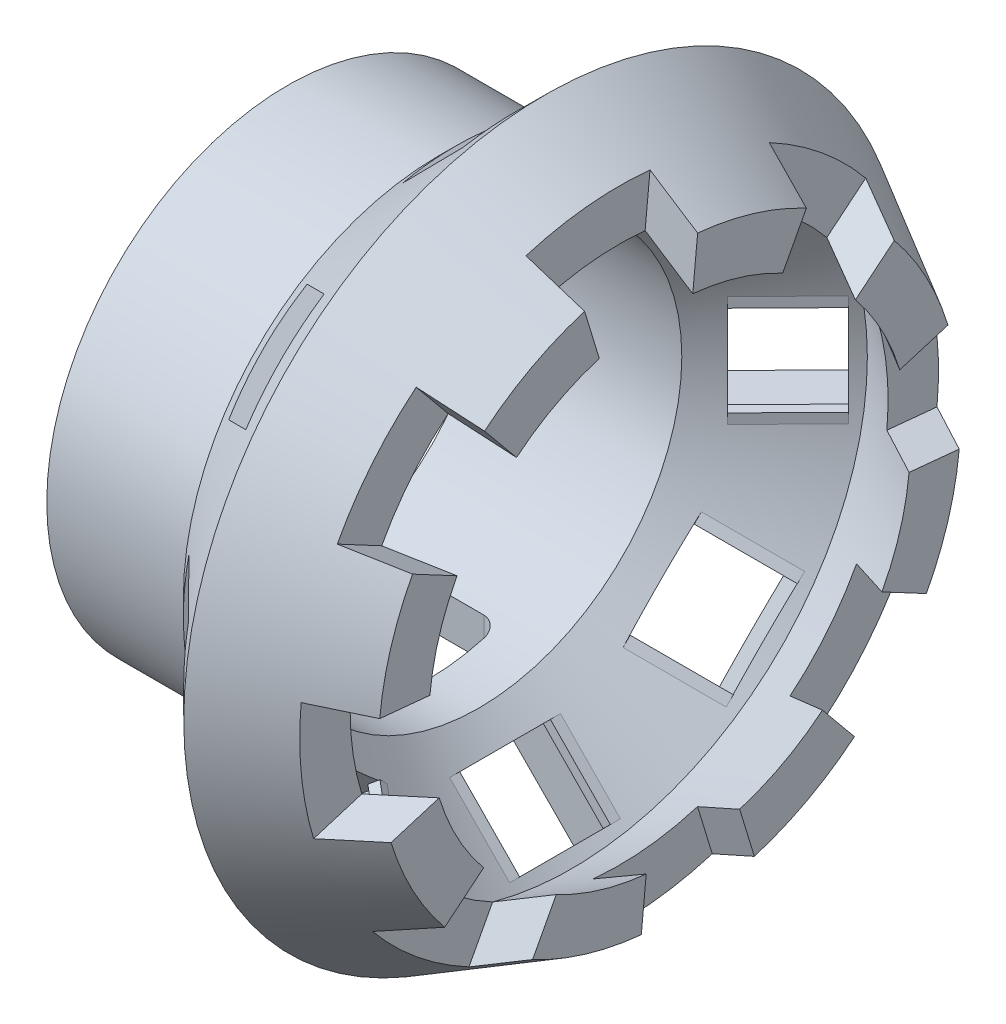
from build123d import *

# Parameters (mm, degrees)
CUT_EXTRUDE_1_DEPTH      = 1.1
PATTERN_CIRCULAR_1_COUNT = 8
SKETCH_5_W               = 1.700083765
SKETCH_5_H               = 0.2
EXTRUDE_1_DEPTH          = 0.2
SKETCH_6_W               = 5.893961657
SKETCH_6_H               = 11.227162516
SKETCH_6_W_2             = 3.517557102
SKETCH_6_H_2             = 15.129652159
CUT_EXTRUDE_2_DEPTH      = 10
SKETCH_7_W               = 0.2
SKETCH_7_H               = 1.700083765
EXTRUDE_2_DEPTH          = 0.2
PATTERN_CIRCULAR_2_COUNT = 8
CUT_EXTRUDE_3_DEPTH      = 1
SKETCH_10_W              = 2.8
SKETCH_10_H              = 4.363066302
CUT_EXTRUDE_4_DEPTH      = 2.8
FILLET_1_R               = 0.3


with BuildPart() as part:
    # 草图1 → 旋转1 (revolve)
    with BuildSketch(Plane.XY, mode=Mode.PRIVATE) as revolve_1_sk:
        Polygon((8.064664367, 7.169467647), (11.04001847, 5.5), (11.04001847, 4.5), (8.600815036, 5.868634144), (6.754967964, 4.03), (6.050341839, 4.03), (2.954967964, 4.03), (2.954967964, 4.78), (5.954967964, 4.78), (5.954967964, 5.068015203), align=None)
    revolve(revolve_1_sk.sketch.rotate(Axis((0, 0, 0), (1, 0, 0)), 90), axis=Axis((0, 0, 0), (1, 0, 0)))

    # 草图2 → 切除-拉伸1 (cut, symmetric)
    with BuildSketch(Plane(origin=(0, 0, 0), x_dir=(1, 0, 0), z_dir=(0, 1, 0))):
        Polygon((5.180344488, -6.508182903), (7.398791823, -4.289735569), (8.600873351, -5.491817097), (6.382426016, -7.710264431), align=None)
    cut_extrude_1 = extrude(amount=CUT_EXTRUDE_1_DEPTH, both=True, mode=Mode.SUBTRACT)

    # 阵列(圆周)1: 切除-拉伸1 ×8 about axis
    pattern_circular_1_axis = Axis((0, 0, 0), (1, 0, 0))
    for i in range(1, PATTERN_CIRCULAR_1_COUNT):
        add(cut_extrude_1.rotate(pattern_circular_1_axis, i * 360 / PATTERN_CIRCULAR_1_COUNT), mode=Mode.SUBTRACT)

    # 草图5 → 凸台-拉伸1 (add)
    with BuildSketch(Plane(origin=(1.503662278, 0, -1.474101418), x_dir=(-0.700052695670969, 0, -0.7140911869529059), z_dir=(0.7140911869529059, 0, -0.700052695670969))):
        with Locations((-9.094582396, 1)):
            Rectangle(SKETCH_5_W, SKETCH_5_H)
        with Locations((-9.094582396, -1)):
            Rectangle(SKETCH_5_W, SKETCH_5_H)
    extrude(amount=-EXTRUDE_1_DEPTH)

    # 草图6 → 切除-拉伸2 (cut, symmetric)
    with BuildSketch(Plane.XY):
        with Locations((0.007987136, 0.100063837)):
            Rectangle(SKETCH_6_W, SKETCH_6_H)
        with Locations((12.298797021, -0.150095755)):
            Rectangle(SKETCH_6_W_2, SKETCH_6_H_2)
    extrude(amount=CUT_EXTRUDE_2_DEPTH, both=True, mode=Mode.SUBTRACT)

    # 草图7 → 凸台-拉伸2 (add)
    with BuildSketch(Plane(origin=(1.503662278, -1.474101418, 0), x_dir=(0, 0, 1), z_dir=(-0.7140911869529061, 0.7000526956709687, 6.88891825891904e-15))):
        with Locations((1, 9.094582396)):
            Rectangle(SKETCH_7_W, SKETCH_7_H)
        with Locations((-1, 9.094582396)):
            Rectangle(SKETCH_7_W, SKETCH_7_H)
    extrude_2 = extrude(amount=EXTRUDE_2_DEPTH)

    # 阵列(圆周)2: 凸台-拉伸2 ×8 about axis
    pattern_circular_2_axis = Axis((0, 0, 0), (1, 0, 0))
    for i in range(1, PATTERN_CIRCULAR_2_COUNT):
        add(extrude_2.rotate(pattern_circular_2_axis, i * 360 / PATTERN_CIRCULAR_2_COUNT))

    # 草图9 → 切除-拉伸3 (cut)
    with BuildSketch(Plane(origin=(10.54001847, 0, 0), x_dir=(0, 0, -1), z_dir=(1, 0, 0))):
        with BuildLine():
            Line((-2.197785116, 7.210789857), (0, 0))
            Line((0, 0), (0.728961128, 7.502957114))
            ThreePointArc((0.728961128, 7.502957114), (-0.748799976, 7.501003158), (-2.197785116, 7.210789857))
        make_face()
        with BuildLine():
            Line((3.544729647, 6.652867165), (0, 0))
            Line((0, 0), (5.820845211, 4.789938498))
            ThreePointArc((5.820845211, 4.789938498), (4.774528658, 5.833491739), (3.544729647, 6.652867165))
        make_face()
        with BuildLine():
            Line((7.210789857, 2.197785116), (0, 0))
            Line((0, 0), (7.502957114, -0.728961128))
            ThreePointArc((7.502957114, -0.728961128), (7.501003158, 0.748799976), (7.210789857, 2.197785116))
        make_face()
        with BuildLine():
            Line((6.652867165, -3.544729647), (0, 0))
            Line((0, 0), (4.789938498, -5.820845211))
            ThreePointArc((4.789938498, -5.820845211), (5.833491739, -4.774528658), (6.652867165, -3.544729647))
        make_face()
        with BuildLine():
            Line((2.197785116, -7.210789857), (0, 0))
            Line((0, 0), (-0.728961128, -7.502957114))
            ThreePointArc((-0.728961128, -7.502957114), (0.748799976, -7.501003158), (2.197785116, -7.210789857))
        make_face()
        with BuildLine():
            Line((-3.544729647, -6.652867165), (0, 0))
            Line((0, 0), (-5.820845211, -4.789938498))
            ThreePointArc((-5.820845211, -4.789938498), (-4.774528658, -5.833491739), (-3.544729647, -6.652867165))
        make_face()
        with BuildLine():
            Line((-7.210789857, -2.197785116), (0, 0))
            Line((0, 0), (-7.502957114, 0.728961128))
            ThreePointArc((-7.502957114, 0.728961128), (-7.501003158, -0.748799976), (-7.210789857, -2.197785116))
        make_face()
        with BuildLine():
            Line((-6.652867165, 3.544729647), (0, 0))
            Line((0, 0), (-4.789938498, 5.820845211))
            ThreePointArc((-4.789938498, 5.820845211), (-5.833491739, 4.774528658), (-6.652867165, 3.544729647))
        make_face()
    extrude(amount=-CUT_EXTRUDE_3_DEPTH, mode=Mode.SUBTRACT)

    # 草图10 → 切除-拉伸4 (cut)
    with BuildSketch(Plane.ZY.offset(-2.954967964)):
        with Locations((0, -3.128262499)):
            Rectangle(SKETCH_10_W, SKETCH_10_H)
    extrude(amount=-CUT_EXTRUDE_4_DEPTH, mode=Mode.SUBTRACT)

    # 圆角1
    fillet_1_edges = [part.edges().sort_by_distance(p)[0] for p in [
        (2.954967964, -4.174695361, 1.4),
        (2.954967964, -4.174695361, -1.4),
        (5.754967964, -4.174695361, -1.4),
        (5.754967964, -4.174695361, 1.4),
    ]]
    fillet(fillet_1_edges, radius=FILLET_1_R)


solid = part.part
